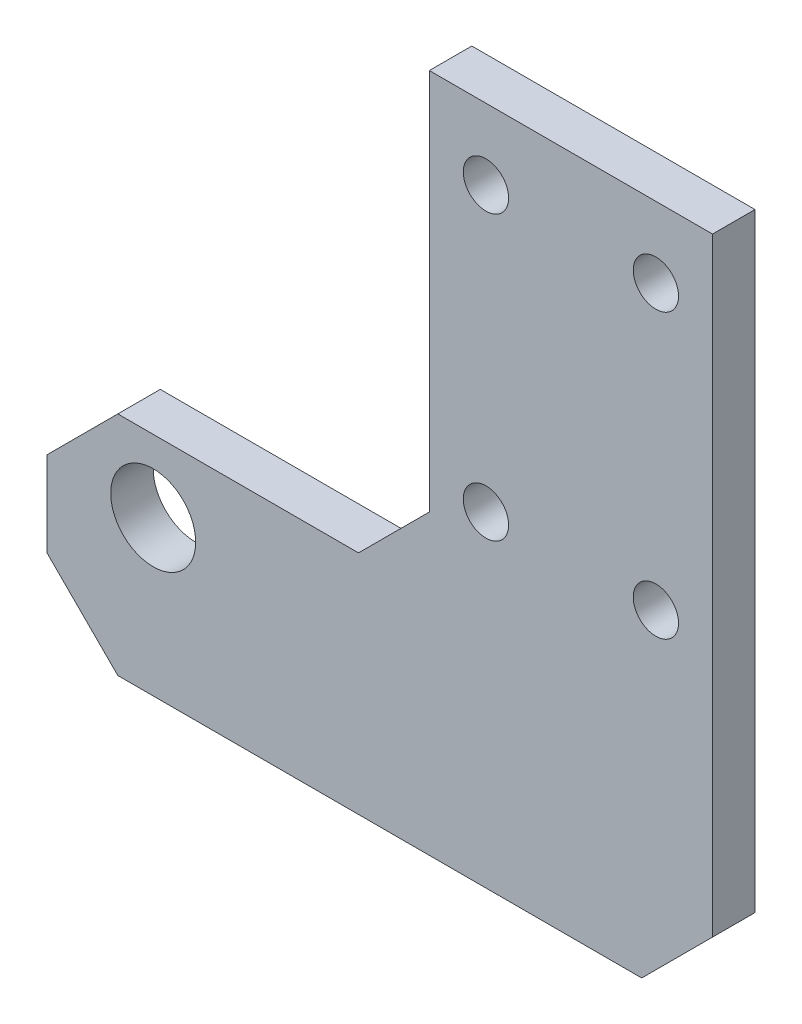
from build123d import *

# Parameters (mm, degrees)
SKETCH1_R           = 3
SKETCH1_R_2         = 1.6
BOSS_EXTRUDE1_DEPTH = 3


with BuildPart() as part:
    # Sketch1 → Boss-Extrude1 (new body)
    with BuildSketch(Plane.XY):
        Polygon((330.61212976, -150), (350.61212976, -150), (350.61212976, -193), (345.61212976, -198), (330.61212976, -198), (308.61212976, -198), (303.61212976, -193), (303.61212976, -187), (308.61212976, -182), (325.61212976, -182), (330.61212976, -177), align=None)
        with Locations((311.11212976, -187.1)):
            Circle(SKETCH1_R, mode=Mode.SUBTRACT)
        with Locations((334.61212976, -155)):
            Circle(SKETCH1_R_2, mode=Mode.SUBTRACT)
        with Locations((346.61212976, -155)):
            Circle(SKETCH1_R_2, mode=Mode.SUBTRACT)
        with Locations((334.61212976, -175)):
            Circle(SKETCH1_R_2, mode=Mode.SUBTRACT)
        with Locations((346.61212976, -175)):
            Circle(SKETCH1_R_2, mode=Mode.SUBTRACT)
    extrude(amount=BOSS_EXTRUDE1_DEPTH)


solid = part.part
